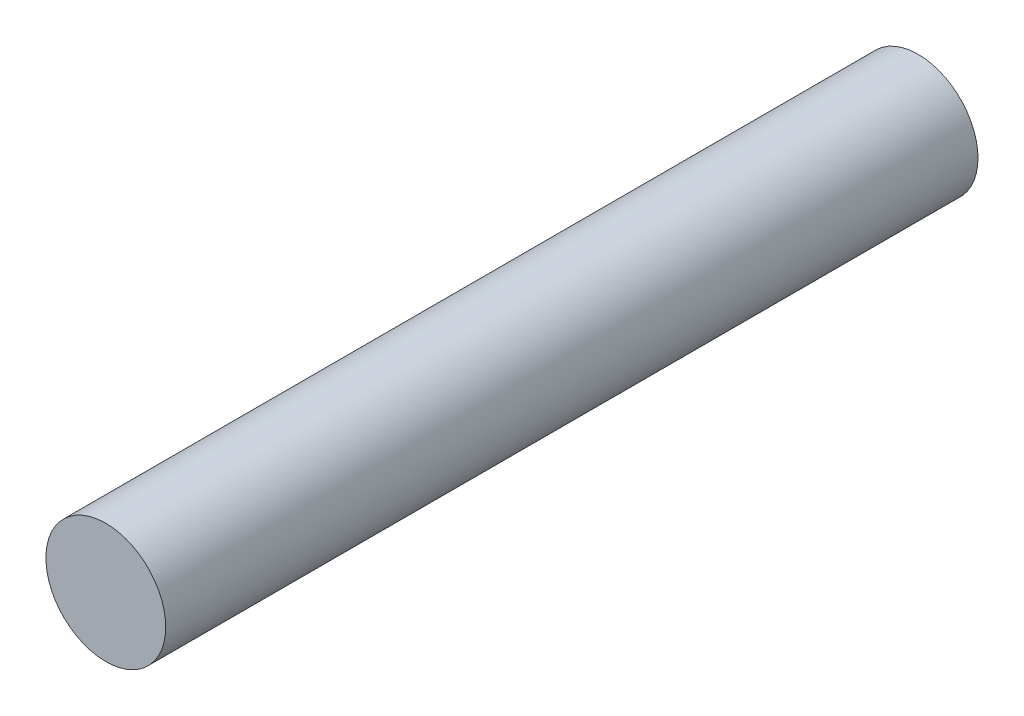
from build123d import *

# Parameters (mm, degrees)
BOSS_EXTRUDE1_DEPTH      = 10
BOSS_EXTRUDE1_DEPTH_BACK = 10
SKETCH1_R                = 1.475


with BuildPart() as part:
    # Sketch1 → Boss-Extrude1 (new, two sides: drawn at the far end of the back side and taken through both)
    with BuildSketch(Plane.XY.offset(-BOSS_EXTRUDE1_DEPTH_BACK)):
        Circle(SKETCH1_R)
    extrude(amount=BOSS_EXTRUDE1_DEPTH + BOSS_EXTRUDE1_DEPTH_BACK)


solid = part.part
